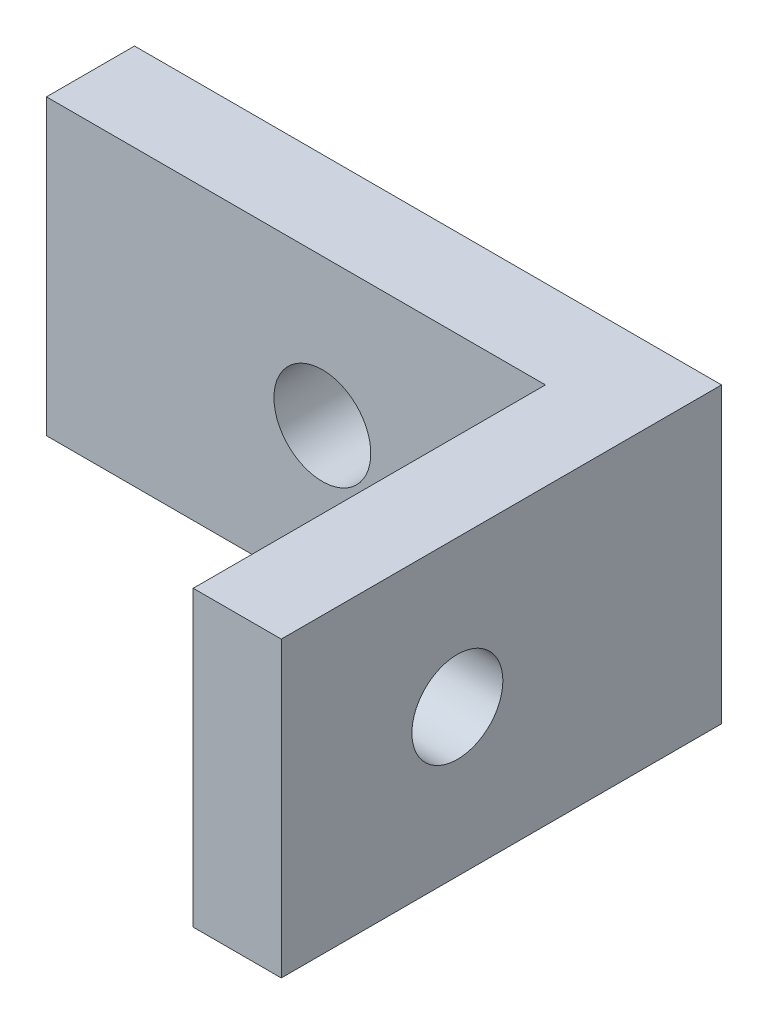
from build123d import *

# Parameters (mm, degrees)
BOSS_EXTRUDE1_DEPTH = 10
CUT_EXTRUDE1_REACH  = 22
SKETCH2_R           = 1.55
CUT_EXTRUDE2_REACH  = 17
SKETCH3_R           = 1.65


with BuildPart() as part:
    # Sketch1 → Boss-Extrude1 (new body)
    with BuildSketch(Plane(origin=(0, 0, 0), x_dir=(1, 0, 0), z_dir=(0, 1, 0))):
        Polygon((0, 0), (17, 0), (17, -12), (20, -12), (20, 3), (0, 3), align=None)
    extrude(amount=BOSS_EXTRUDE1_DEPTH)

    # Sketch2 → Cut-Extrude1 (cut, up to next)
    with BuildSketch(Plane(origin=(20, 0, 0), x_dir=(0, 0, -1), z_dir=(1, 0, 0)), mode=Mode.PRIVATE) as cut_extrude1_sk1:
        with Locations((-6, 5)):
            Circle(SKETCH2_R)
    cut_extrude1_tool1 = extrude(cut_extrude1_sk1.sketch, amount=-CUT_EXTRUDE1_REACH, mode=Mode.PRIVATE) & part.part
    add(cut_extrude1_tool1.solids().sort_by_distance((20, 5, 6))[0], mode=Mode.SUBTRACT)

    # Sketch3 → Cut-Extrude2 (cut, up to next)
    with BuildSketch(Plane(origin=(0, 0, -3), x_dir=(-1, 0, 0), z_dir=(0, 0, -1)), mode=Mode.PRIVATE) as cut_extrude2_sk1:
        with Locations((-9.4, 5)):
            Circle(SKETCH3_R)
    cut_extrude2_tool1 = extrude(cut_extrude2_sk1.sketch, amount=-CUT_EXTRUDE2_REACH, mode=Mode.PRIVATE) & part.part
    add(cut_extrude2_tool1.solids().sort_by_distance((9.4, 5, -3))[0], mode=Mode.SUBTRACT)


solid = part.part
